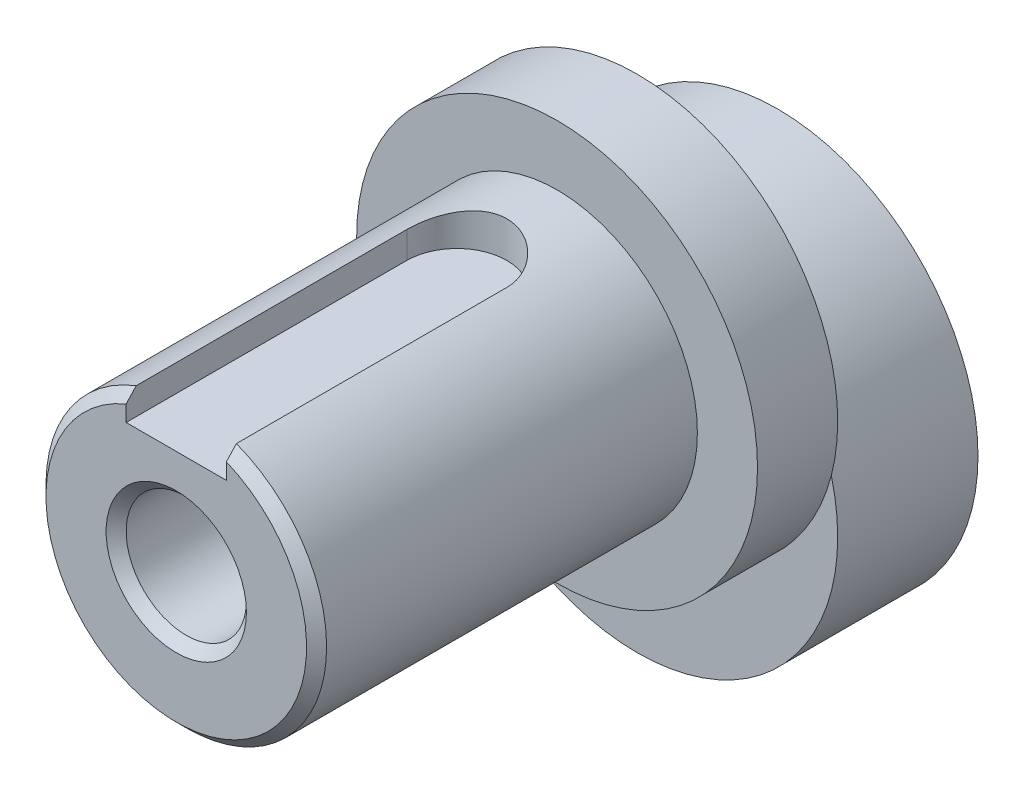
from build123d import *

# Parameters (mm, degrees)
SKETCH2_R           = 10
BOSS_EXTRUDE1_DEPTH = 7
SKETCH3_R           = 10
BOSS_EXTRUDE2_DEPTH = 4
SKETCH4_R           = 7
BOSS_EXTRUDE3_DEPTH = 19
SKETCH5_R           = 3
CUT_EXTRUDE1_DEPTH  = 31
CHAMFER1_SIZE       = 0.5
CUT_EXTRUDE3_START  = 10.2
CUT_EXTRUDE3_DEPTH  = 5.8
CHAMFER2_SIZE       = 0.5


with BuildPart() as part:
    # Sketch2 → Boss-Extrude1 (new body)
    with BuildSketch(Plane.XY):
        Circle(SKETCH2_R)
    extrude(amount=BOSS_EXTRUDE1_DEPTH)

    # Sketch3 → Boss-Extrude2 (add)
    with BuildSketch(Plane.XY.offset(7)):
        with Locations((0, 5)):
            Circle(SKETCH3_R)
    extrude(amount=BOSS_EXTRUDE2_DEPTH)

    # Sketch4 → Boss-Extrude3 (add)
    with BuildSketch(Plane.XY.offset(11)):
        with Locations((0, 5)):
            Circle(SKETCH4_R)
    extrude(amount=BOSS_EXTRUDE3_DEPTH)

    # Sketch5 → Cut-Extrude1 (cut, through all)
    with BuildSketch(Plane.XY.offset(30)):
        with Locations((0, 5)):
            Circle(SKETCH5_R)
    extrude(amount=-CUT_EXTRUDE1_DEPTH, mode=Mode.SUBTRACT)

    # Chamfer1
    chamfer1_edges = [part.edges().sort_by_distance(p)[0] for p in [
        (-3, 5, 0),
        (-3, 5, 30),
    ]]
    chamfer(chamfer1_edges, length=CHAMFER1_SIZE)

    # Sketch6 → Cut-Extrude3 (cut, through all)
    with BuildSketch(Plane(origin=(0, 0, 0), x_dir=(1, 0, 0), z_dir=(0, 1, 0)).offset(CUT_EXTRUDE3_START)):
        with BuildLine():
            Line((-2.5, -16), (-2.5, -31.730265833))
            Line((-2.5, -31.730265833), (2.5, -31.730265833))
            Line((2.5, -31.730265833), (2.5, -16))
            ThreePointArc((2.5, -16), (0, -13.5), (-2.5, -16))
        make_face()
    extrude(amount=CUT_EXTRUDE3_DEPTH, mode=Mode.SUBTRACT)

    # Chamfer2
    chamfer2_edges = [part.edges().sort_by_distance(p)[0] for p in [
        (-3.968626967, -0.766281297, 30),
    ]]
    chamfer(chamfer2_edges, length=CHAMFER2_SIZE)


solid = part.part
